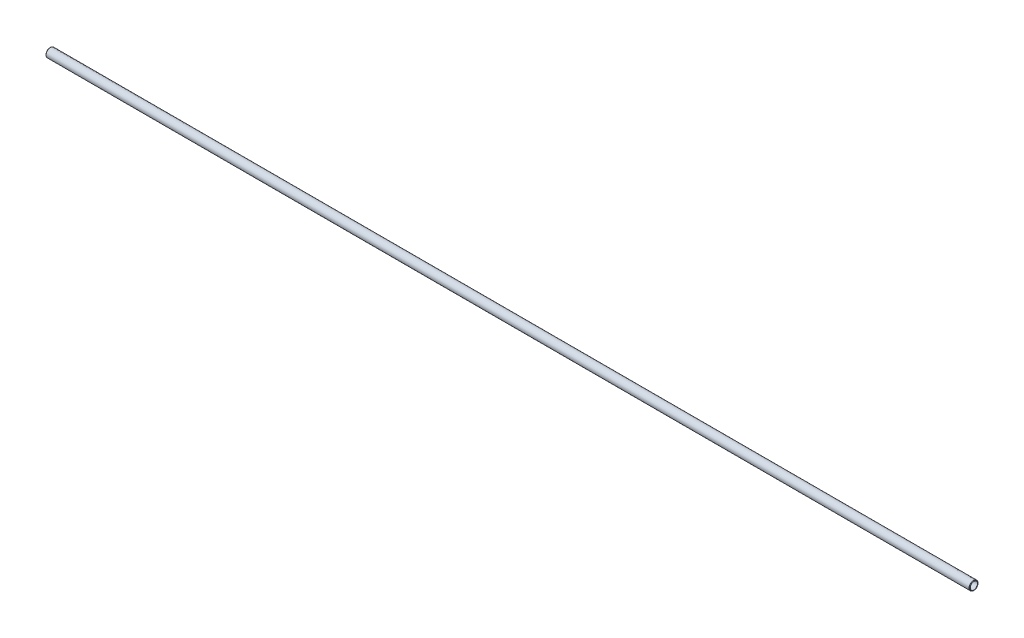
from build123d import *


with BuildPart() as part:
    # Sketch1 → Revolve1 (revolve)
    with BuildSketch(Plane.XY):
        with BuildLine():
            Line((-0.396407684, 5.304957684), (-0.254, 5.16255))
            Line((-0.254, 5.16255), (0, 5.16255))
            Line((0, 5.16255), (0.508, 5.67055))
            Line((0.508, 5.67055), (1289.05, 5.67055))
            Line((1289.05, 5.67055), (1289.558, 5.16255))
            Line((1289.558, 5.16255), (1289.812, 5.16255))
            Line((1289.812, 5.16255), (1289.954407684, 5.304957684))
            ThreePointArc((1289.954407684, 5.304957684), (1289.991605122, 5.394760245), (1289.954407684, 5.484562806))
            Line((1289.954407684, 5.484562806), (1289.421910245, 6.017060245))
            ThreePointArc((1289.421910245, 6.017060245), (1289.257103184, 6.127180803), (1289.0627, 6.16585))
            Line((1289.0627, 6.16585), (0.4953, 6.16585))
            ThreePointArc((0.4953, 6.16585), (0.300896816, 6.127180803), (0.136089755, 6.017060245))
            Line((0.136089755, 6.017060245), (-0.396407684, 5.484562806))
            ThreePointArc((-0.396407684, 5.484562806), (-0.433605122, 5.394760245), (-0.396407684, 5.304957684))
        make_face()
    revolve(axis=Axis((1289.558, 0, 0), (-1, 0, 0)))


solid = part.part
